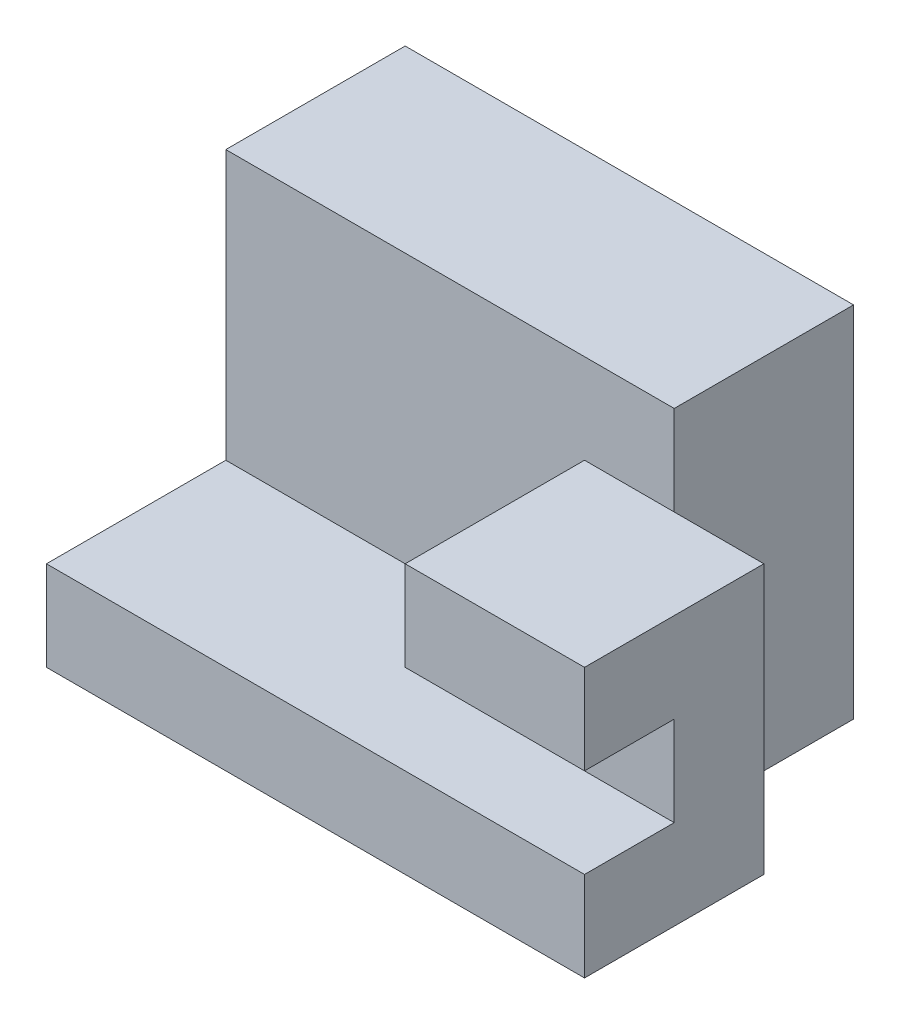
from build123d import *

# Parameters (mm, degrees)
SKETCH_1_W      = 25
SKETCH_1_H      = 10
EXTRUDE_1_DEPTH = 20
EXTRUDE_2_DEPTH = 5
EXTRUDE_3_DEPTH = 10


with BuildPart() as part:
    # 草圖1 → 填料-伸長1 (new body)
    with BuildSketch(Plane(origin=(0, 0, 0), x_dir=(1, 0, 0), z_dir=(0, 1, 0))):
        with Locations((12.5, 5)):
            Rectangle(SKETCH_1_W, SKETCH_1_H)
    extrude(amount=EXTRUDE_1_DEPTH)

    # 草圖1<3> → 填料-伸長2 (add)
    with BuildSketch(Plane(origin=(0, 0, 0), x_dir=(1, 0, 0), z_dir=(0, 1, 0))):
        Polygon((25, 0), (0, 0), (0, -10), (30, -10), (30, 0), align=None)
    extrude(amount=EXTRUDE_2_DEPTH)

    # 草圖2 → 填料-伸長3 (add)
    with BuildSketch(Plane(origin=(30, 0, 0), x_dir=(0, 0, -1), z_dir=(1, 0, 0))):
        Polygon((-5, 5), (0, 5), (0, 11.350931175), (0, 15), (-10, 15), (-10, 10), (-5, 10), align=None)
    extrude(amount=-EXTRUDE_3_DEPTH)


solid = part.part
